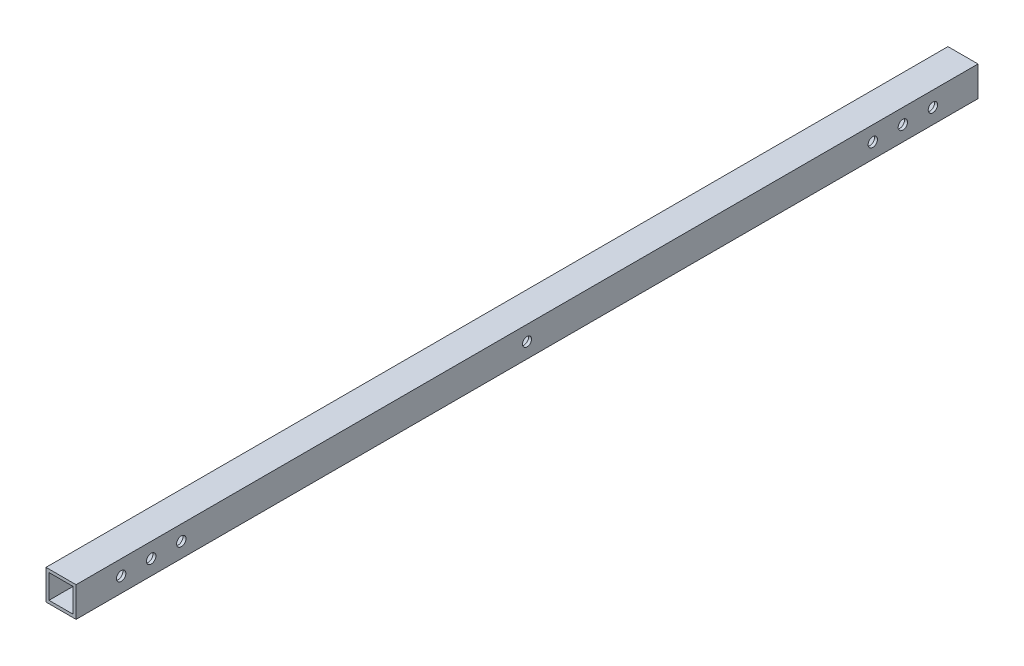
from build123d import *

# Parameters (mm, degrees)
SKETCH_1_W          = 300
SKETCH_1_H          = 10
SKETCH_1_R          = 1.558433933
EXTRUDE_4_DEPTH     = 10
SKETCH_5_R          = 1.5
CUT_EXTRUDE_1_DEPTH = 10
SKETCH_9_W          = 8
SKETCH_9_H          = 8
CUT_EXTRUDE_4_DEPTH = 300


with BuildPart() as part:
    # 草图1 → 凸台-拉伸4 (new body)
    with BuildSketch(Plane(origin=(0, 0, 0), x_dir=(0, 0, -1), z_dir=(1, 0, 0))):
        with Locations((95.027173063, 0.135119806)):
            Rectangle(SKETCH_1_W, SKETCH_1_H)
        with Locations((-39.972826937, 0.135119806)):
            Circle(SKETCH_1_R, mode=Mode.SUBTRACT)
        with Locations((-29.972826937, 0.135119806)):
            Circle(SKETCH_1_R, mode=Mode.SUBTRACT)
        with Locations((-19.972826937, 0.135119806)):
            Circle(SKETCH_1_R, mode=Mode.SUBTRACT)
        with Locations((210.027173063, 0.135119806)):
            Circle(SKETCH_1_R, mode=Mode.SUBTRACT)
        with Locations((220.027173063, 0.135119806)):
            Circle(SKETCH_1_R, mode=Mode.SUBTRACT)
        with Locations((230.027173063, 0.135119806)):
            Circle(SKETCH_1_R, mode=Mode.SUBTRACT)
    extrude(amount=EXTRUDE_4_DEPTH)

    # 草图5 → 切除-拉伸1 (cut)
    with BuildSketch(Plane(origin=(10, 0, 0), x_dir=(0, 0, -1), z_dir=(1, 0, 0))):
        with Locations((95.027173063, 0.135119806)):
            Circle(SKETCH_5_R)
    extrude(amount=-CUT_EXTRUDE_1_DEPTH, mode=Mode.SUBTRACT)

    # 草图9 → 切除-拉伸4 (cut)
    with BuildSketch(Plane.XY.offset(54.972826937)):
        with Locations((5, 0.135119806)):
            Rectangle(SKETCH_9_W, SKETCH_9_H)
    extrude(amount=-CUT_EXTRUDE_4_DEPTH, mode=Mode.SUBTRACT)


solid = part.part
